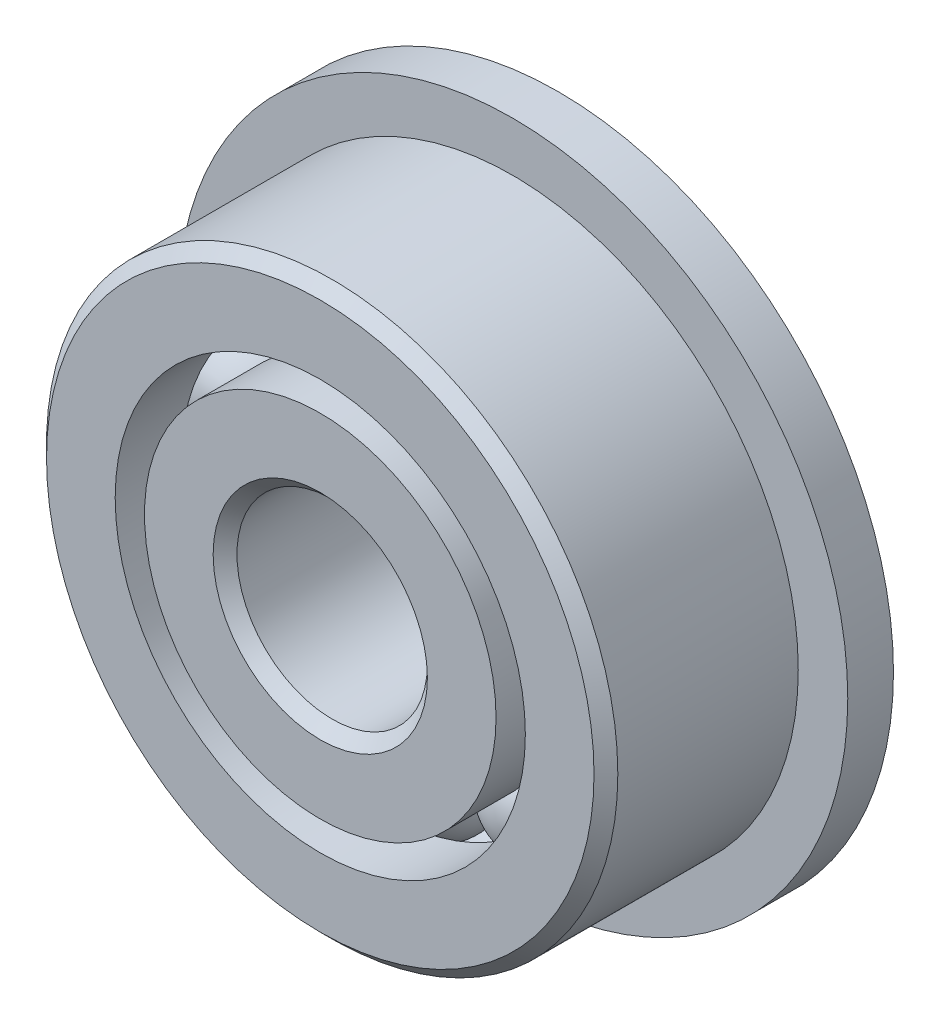
from build123d import *

# Parameters (mm, degrees)
CIRPATTERN1_COUNT = 10
SKETCH6_W         = 0.762
SKETCH6_H         = 2.168769231


with BuildPart() as part:
    # Sketch1 → Revolve1 (revolve)
    with BuildSketch(Plane(origin=(0, 0, 0), x_dir=(0, 0, -1), z_dir=(1, 0, 0))):
        with BuildLine():
            Line((1.7859375, 4.7625), (-1.7859375, 4.7625))
            Line((-1.7859375, 4.7625), (-1.984375, 4.5640625))
            Line((-1.984375, 4.5640625), (-1.984375, 3.419230769))
            Line((-1.984375, 3.419230769), (-0.881944444, 3.419230769))
            ThreePointArc((-0.881944444, 3.419230769), (0, 4.090136422), (0.881944444, 3.419230769))
            Line((0.881944444, 3.419230769), (1.984375, 3.419230769))
            Line((1.984375, 3.419230769), (1.984375, 4.5640625))
            Line((1.984375, 4.5640625), (1.7859375, 4.7625))
        make_face()
    revolve(axis=Axis((0, 0, 1.984375), (0, 0, -1)))

    # Sketch6 → Revolve6 (revolve)
    with BuildSketch(Plane(origin=(0, 0, 0), x_dir=(0, 0, -1), z_dir=(1, 0, 0))):
        with Locations((1.603375, 4.503615384)):
            Rectangle(SKETCH6_W, SKETCH6_H)
    revolve(axis=Axis((0, 0, -1.984375), (0, 0, 1)))


with BuildPart() as body_2:
    # Sketch3 → Revolve3 (revolve)
    with BuildSketch(Plane(origin=(0, 0, 0), x_dir=(0, 0, -1), z_dir=(1, 0, 0))):
        with BuildLine():
            Line((-1.984375, 2.930769231), (-0.881944444, 2.930769231))
            ThreePointArc((-0.881944444, 2.930769231), (0, 2.259863578), (0.881944444, 2.930769231))
            Line((0.881944444, 2.930769231), (1.984375, 2.930769231))
            Line((1.984375, 2.930769231), (1.984375, 1.7859375))
            Line((1.984375, 1.7859375), (1.7859375, 1.5875))
            Line((1.7859375, 1.5875), (-1.7859375, 1.5875))
            Line((-1.7859375, 1.5875), (-1.984375, 1.7859375))
            Line((-1.984375, 1.7859375), (-1.984375, 2.930769231))
        make_face()
    revolve(axis=Axis((0, 0, 1.984375), (0, 0, -1)))


with BuildPart() as body_3:
    # Sketch4 → Revolve4 (revolve)
    with BuildSketch(Plane(origin=(0, 0, 0), x_dir=(0, 0, -1), z_dir=(1, 0, 0))):
        with BuildLine():
            Line((-0.915136422, 3.175), (0.915136422, 3.175))
            ThreePointArc((0.915136422, 3.175), (0, 4.090136422), (-0.915136422, 3.175))
        make_face()
    revolve(axis=Axis((0, 3.175, 0.915136422), (0, 0, -1)))


with BuildPart() as cirpattern1_1:
    # CirPattern1: pattern copy
    add(body_3.part.rotate(Axis((0, 0, -1.984375), (0, 0, 1)), 1 * 360 / CIRPATTERN1_COUNT))


with BuildPart() as cirpattern1_2:
    # CirPattern1: pattern copy
    add(body_3.part.rotate(Axis((0, 0, -1.984375), (0, 0, 1)), 2 * 360 / CIRPATTERN1_COUNT))


with BuildPart() as cirpattern1_3:
    # CirPattern1: pattern copy
    add(body_3.part.rotate(Axis((0, 0, -1.984375), (0, 0, 1)), 3 * 360 / CIRPATTERN1_COUNT))


with BuildPart() as cirpattern1_4:
    # CirPattern1: pattern copy
    add(body_3.part.rotate(Axis((0, 0, -1.984375), (0, 0, 1)), 4 * 360 / CIRPATTERN1_COUNT))


with BuildPart() as cirpattern1_5:
    # CirPattern1: pattern copy
    add(body_3.part.rotate(Axis((0, 0, -1.984375), (0, 0, 1)), 5 * 360 / CIRPATTERN1_COUNT))


with BuildPart() as cirpattern1_6:
    # CirPattern1: pattern copy
    add(body_3.part.rotate(Axis((0, 0, -1.984375), (0, 0, 1)), 6 * 360 / CIRPATTERN1_COUNT))


with BuildPart() as cirpattern1_7:
    # CirPattern1: pattern copy
    add(body_3.part.rotate(Axis((0, 0, -1.984375), (0, 0, 1)), 7 * 360 / CIRPATTERN1_COUNT))


with BuildPart() as cirpattern1_8:
    # CirPattern1: pattern copy
    add(body_3.part.rotate(Axis((0, 0, -1.984375), (0, 0, 1)), 8 * 360 / CIRPATTERN1_COUNT))


with BuildPart() as cirpattern1_9:
    # CirPattern1: pattern copy
    add(body_3.part.rotate(Axis((0, 0, -1.984375), (0, 0, 1)), 9 * 360 / CIRPATTERN1_COUNT))


solid = Compound([part.part, body_2.part, body_3.part, cirpattern1_1.part, cirpattern1_2.part, cirpattern1_3.part, cirpattern1_4.part, cirpattern1_5.part, cirpattern1_6.part, cirpattern1_7.part, cirpattern1_8.part, cirpattern1_9.part])
